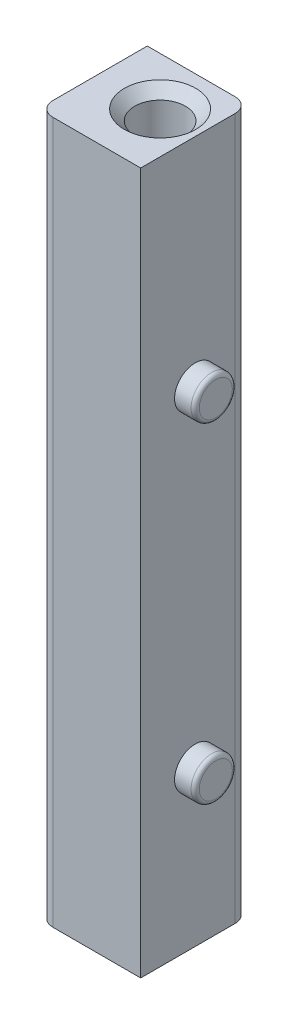
from build123d import *

# Parameters (mm, degrees)
SKETCH1_W                = 12.5984
SKETCH1_H                = 13.4112
BOSS_EXTRUDE1_DEPTH      = 46.99
BOSS_EXTRUDE1_DEPTH_BACK = 39.37
SKETCH2_R                = 3.1242
CUT_EXTRUDE1_DEPTH       = 87.36
SKETCH4_R                = 2.54
BOSS_EXTRUDE2_DEPTH      = 2.54
FILLET2_R                = 0.508
FILLET2_OF_MIRROR1_R     = 0.508
FILLET1_R                = 1.778
CHAMFER1_SIZE            = 1.27


with BuildPart() as part:
    # Sketch1 → Boss-Extrude1 (new body, two sides)
    with BuildSketch(Plane(origin=(0, 0, 0), x_dir=(1, 0, 0), z_dir=(0, 1, 0))) as boss_extrude1_sk:
        with Locations((-1.1938, -0.7874)):
            Rectangle(SKETCH1_W, SKETCH1_H)
    extrude(amount=BOSS_EXTRUDE1_DEPTH)
    extrude(boss_extrude1_sk.sketch, amount=-BOSS_EXTRUDE1_DEPTH_BACK)

    # Sketch2 → Cut-Extrude1 (cut, through all)
    with BuildSketch(Plane(origin=(0, 46.99, 0), x_dir=(1, 0, 0), z_dir=(0, 1, 0))):
        with Locations(Location((0, 0, 0), (0, 0, 270))):  # turned: the seam where the file's is
            Circle(SKETCH2_R)
    extrude(amount=-CUT_EXTRUDE1_DEPTH, mode=Mode.SUBTRACT)

    # Sketch4 → Boss-Extrude2 (add)
    with BuildSketch(Plane(origin=(5.1054, 0, 0), x_dir=(0, 0, -1), z_dir=(1, 0, 0))):
        with Locations((-0.7874, -20.32)):
            Circle(SKETCH4_R)
    boss_extrude2 = extrude(amount=BOSS_EXTRUDE2_DEPTH)

    # Fillet2
    fillet2_edges = [part.edges().sort_by_distance(p)[0] for p in [
        (7.6454, -20.32, 3.3274),
    ]]
    fillet(fillet2_edges, radius=FILLET2_R)

    # Mirror1: Boss-Extrude2 across plane
    add(boss_extrude2.mirror(Plane.ZX))

    # Fillet2 of Mirror1
    fillet2_of_mirror1_edges = [part.edges().sort_by_distance(p)[0] for p in [
        (7.6454, 20.32, 3.3274),
    ]]
    fillet(fillet2_of_mirror1_edges, radius=FILLET2_OF_MIRROR1_R)

    # Fillet1
    fillet1_edges = [part.edges().sort_by_distance(p)[0] for p in [
        (5.1054, 3.81, -5.9182),
        (-7.493, 3.81, 7.493),
    ]]
    fillet(fillet1_edges, radius=FILLET1_R)

    # Chamfer1
    chamfer1_edges = [part.edges().sort_by_distance(p)[0] for p in [
        (0, 46.99, -3.1242),
    ]]
    chamfer(chamfer1_edges, length=CHAMFER1_SIZE)


solid = part.part
